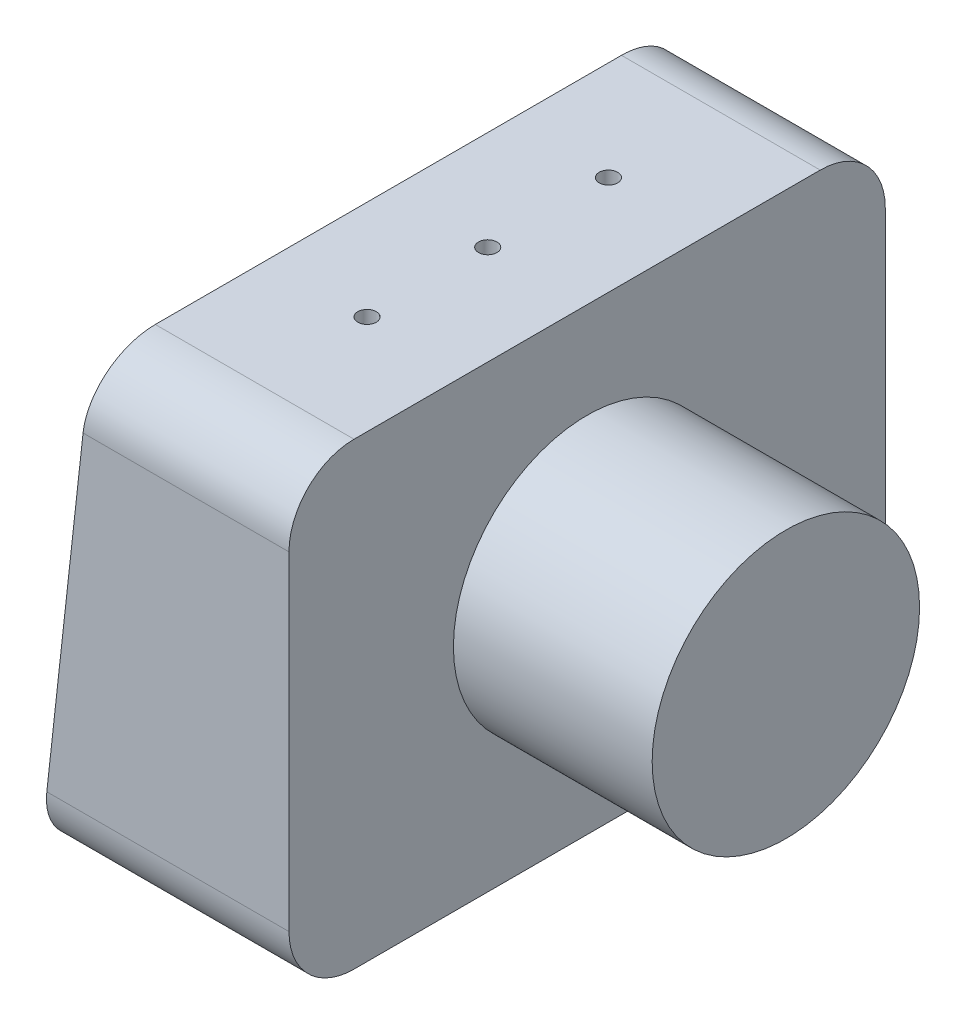
from build123d import *

# Parameters (mm, degrees)
EXTRUDE_1_DEPTH           = 165
FILLET_1_R                = 18
SKETCH_2_R                = 37
EXTRUDE_2_DEPTH           = 55
HOLE_WIZARD_1_4_201_D     = 5.1054
HOLE_WIZARD_1_4_201_DEPTH = 12
HOLE_WIZARD_1_4_201_TIP   = 1.533816902
HOLE_WIZARD_1_4_202_D     = 5.1054
HOLE_WIZARD_1_4_202_DEPTH = 12
HOLE_WIZARD_1_4_202_TIP   = 1.533816902
EXTRUDE_3_DEPTH           = 1
SKETCH_10_OUTSIDE_W       = 215.504
SKETCH_10_OUTSIDE_H       = 190.363
SKETCH_10_OUTSIDE_W_2     = 121.90164915
SKETCH_10_OUTSIDE_H_2     = 79.127933184
CUT_EXTRUDE_1_DEPTH       = 0.5


with BuildPart() as part:
    # Эскиз1 → Бобышка-Вытянуть1 (new body)
    with BuildSketch(Plane.XY):
        Polygon((0, 0), (0, 127), (-55, 127), (-69, 0), align=None)
    extrude(amount=EXTRUDE_1_DEPTH)

    # Скругление1
    fillet_1_edges = [part.edges().sort_by_distance(p)[0] for p in [
        (-27.5, 127, 165),
        (-34.5, 0, 165),
        (-27.5, 127, 0),
        (-34.5, 0, 0),
    ]]
    fillet(fillet_1_edges, radius=FILLET_1_R)

    # Эскиз2 → Бобышка-Вытянуть2 (add)
    with BuildSketch(Plane(origin=(0, 0, 0), x_dir=(0, 0, -1), z_dir=(1, 0, 0))):
        with Locations((-82.5, 63.5)):
            Circle(SKETCH_2_R)
    extrude(amount=EXTRUDE_2_DEPTH)

    # Отверстие обработанное метчиком 1/4-201
    with Locations(Plane(origin=(0, 127, 0), x_dir=(1, 0, 0), z_dir=(0, 1, 0))):
        with Locations((-27.5, -49.1), (-27.5, -82.5), (-27.5, -115.9)):
            Hole(HOLE_WIZARD_1_4_201_D / 2, depth=HOLE_WIZARD_1_4_201_DEPTH)
            with Locations((0, 0, -(HOLE_WIZARD_1_4_201_DEPTH + HOLE_WIZARD_1_4_201_TIP / 2))):  # 118° drill point
                Cone(0, HOLE_WIZARD_1_4_201_D / 2, HOLE_WIZARD_1_4_201_TIP, mode=Mode.SUBTRACT)

    # Отверстие обработанное метчиком 1/4-202
    with Locations(Plane(origin=(0, 0, 0), x_dir=(-1, 0, 0), z_dir=(0, -1, 0))):
        with Locations((34.5, -82.5)):
            Hole(HOLE_WIZARD_1_4_202_D / 2, depth=HOLE_WIZARD_1_4_202_DEPTH)
            with Locations((0, 0, -(HOLE_WIZARD_1_4_202_DEPTH + HOLE_WIZARD_1_4_202_TIP / 2))):  # 118° drill point
                Cone(0, HOLE_WIZARD_1_4_202_D / 2, HOLE_WIZARD_1_4_202_TIP, mode=Mode.SUBTRACT)

    # Эскиз9 → Бобышка-Вытянуть3 (add)
    with BuildSketch(Plane(origin=(-68.171577335, 7.514977029, 0), x_dir=(0, 0, 1), z_dir=(-0.99397881, 0.109572467, 0))):
        with BuildLine():
            Line((18, -1.560500239), (147, -1.560500239))
            add(Edge.make_bspline(
                [(147, -1.560500239), (147.795969048, -1.560500239), (148.578437938, -1.48137479), (149.732739087, -1.248968925), (150.114248167, -1.152405098), (150.870602957, -0.920222923), (151.246130664, -0.784060546), (152.337830508, -0.325667383), (153.027835256, 0.048140187), (154.006731596, 0.710119453), (154.325036907, 0.948994101), (154.935136946, 1.45617868), (155.225430555, 1.722967352), (156.053427969, 2.561683199), (156.548653408, 3.171597982), (157.20432669, 4.164420075), (157.407043585, 4.507004661), (157.774884438, 5.203781035), (158.107288123, 5.915340648), (158.369821072, 6.656048071), (158.596915662, 7.41153923), (158.6930429, 7.79849924), (158.923007799, 8.965817399), (159, 9.752769129), (159, 10.548537722)],
                knots=[0, 0, 0, 0, 0.125, 0.125, 0.1875, 0.1875, 0.25, 0.25, 0.375, 0.375, 0.4375, 0.4375, 0.5, 0.5, 0.625, 0.625, 0.6875, 0.6875, 0.75, 0.8125, 0.8125, 0.875, 0.875, 1, 1, 1, 1], degree=3))
            Line((159, 10.548537722), (159, 102.099785192))
            add(Edge.make_bspline(
                [(159, 102.099785192), (159, 102.89567677), (158.92299313, 103.678477169), (158.69658927, 104.833825846), (158.602503189, 105.215776987), (158.376242963, 105.973204292), (158.243333402, 106.350026622), (157.795055135, 107.447066101), (157.429092547, 108.141223603), (156.564023929, 109.455731539), (156.059486079, 110.079699577), (154.955465788, 111.199609881), (154.352820703, 111.702413635), (153.371115524, 112.368877293), (153.029785995, 112.576618568), (152.335786173, 112.953165195), (151.627066488, 113.293348749), (150.889392409, 113.562005098), (150.137062243, 113.794455923), (149.752332485, 113.89282261), (148.583675335, 114.129662505), (147.796097323, 114.208823153), (147, 114.208823153)],
                knots=[0, 0, 0, 0, 0.125, 0.125, 0.1875, 0.1875, 0.25, 0.25, 0.375, 0.375, 0.5, 0.5, 0.625, 0.625, 0.6875, 0.6875, 0.75, 0.8125, 0.8125, 0.875, 0.875, 1, 1, 1, 1], degree=3))
            Line((147, 114.208823153), (18, 114.208823153))
            add(Edge.make_bspline(
                [(18, 114.208823153), (17.204030952, 114.208823153), (16.421562062, 114.129697705), (15.267260913, 113.897291839), (14.885751833, 113.800728013), (14.129397043, 113.568545837), (13.753869336, 113.43238346), (12.662169492, 112.973990297), (11.972164744, 112.600182727), (10.993268404, 111.938203462), (10.674963093, 111.699328814), (10.064863054, 111.192144234), (9.774569445, 110.925355563), (8.946572031, 110.086639716), (8.451346592, 109.476724932), (7.79567331, 108.48390284), (7.592956415, 108.141318253), (7.225115562, 107.444541879), (6.892711877, 106.732982266), (6.630178928, 105.992274843), (6.403084338, 105.236783685), (6.3069571, 104.849823675), (6.076992201, 103.682505516), (6, 102.895553785), (6, 102.099785192)],
                knots=[0, 0, 0, 0, 0.125, 0.125, 0.1875, 0.1875, 0.25, 0.25, 0.375, 0.375, 0.4375, 0.4375, 0.5, 0.5, 0.625, 0.625, 0.6875, 0.6875, 0.75, 0.8125, 0.8125, 0.875, 0.875, 1, 1, 1, 1], degree=3))
            Line((6, 102.099785192), (6, 10.548537722))
            add(Edge.make_bspline(
                [(6, 10.548537722), (6, 9.752646144), (6.07700687, 8.969845746), (6.30341073, 7.814497069), (6.397496811, 7.432545928), (6.623757037, 6.675118622), (6.756666598, 6.298296292), (7.204944865, 5.201256813), (7.570907453, 4.507099312), (8.435976071, 3.192591376), (8.940513921, 2.568623338), (10.044534212, 1.448713034), (10.647179297, 0.945909279), (11.628884476, 0.279445622), (11.970214005, 0.071704346), (12.664213827, -0.30484228), (13.372933512, -0.645025835), (14.110607591, -0.913682184), (14.862937757, -1.146133008), (15.247667515, -1.244499696), (16.416324665, -1.48133959), (17.203902677, -1.560500239), (18, -1.560500239)],
                knots=[0, 0, 0, 0, 0.125, 0.125, 0.1875, 0.1875, 0.25, 0.25, 0.375, 0.375, 0.5, 0.5, 0.625, 0.625, 0.6875, 0.6875, 0.75, 0.8125, 0.8125, 0.875, 0.875, 1, 1, 1, 1], degree=3))
        make_face()
    extrude(amount=EXTRUDE_3_DEPTH)

    # Эскиз10 outside → Вырез-Вытянуть1 (cut)
    with BuildSketch(Plane(origin=(-69.165556145, 7.624549496, 0), x_dir=(0, 0, 1), z_dir=(-0.99397881, 0.109572467, 0))):
        with Locations((82.5, 62.3325)):
            Rectangle(SKETCH_10_OUTSIDE_W, SKETCH_10_OUTSIDE_H)
        with Locations((82.5, 56.324161457)):
            Rectangle(SKETCH_10_OUTSIDE_W_2, SKETCH_10_OUTSIDE_H_2, mode=Mode.SUBTRACT)
    extrude(amount=-CUT_EXTRUDE_1_DEPTH, mode=Mode.SUBTRACT)


solid = part.part
